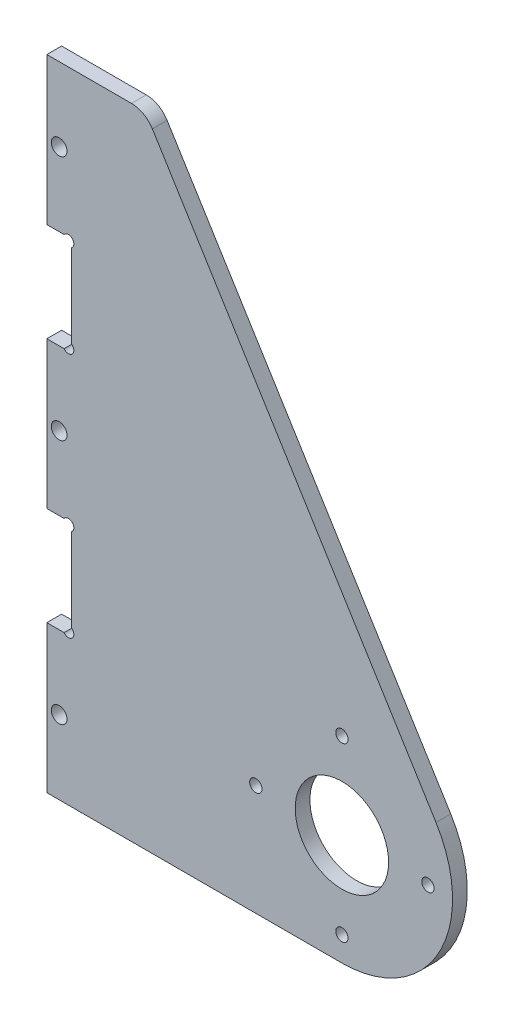
from build123d import *

# Parameters (mm, degrees)
SKETCH_2_R          = 9.5
SKETCH_2_R_2        = 1.25
EXTRUDE_1_DEPTH     = 3
FILLET_3_R          = 5
SKETCH_4_R          = 1.6
SKETCH_4_R_2        = 1.1
SKETCH_4_W          = 5.05
SKETCH_4_H          = 20.1
CUT_EXTRUDE_1_DEPTH = 10


with BuildPart() as part:
    # ｽｹｯﾁ2 → ﾎﾞｽ - 押し出し1 (new body)
    with BuildSketch(Plane.XY):
        with BuildLine():
            Line((-60, 107.5), (-60, -22.5))
            Line((-60, -22.5), (-40, -22.5))
            Line((-40, -22.5), (0, -22.5))
            ThreePointArc((0, -22.5), (19.65247344, -10.9558335), (19.138597944, 11.830641096))
            Line((19.138597944, 11.830641096), (-40, 107.5))
            Line((-40, 107.5), (-60, 107.5))
        make_face()
        Circle(SKETCH_2_R, mode=Mode.SUBTRACT)
        with Locations((0, 17.5)):
            Circle(SKETCH_2_R_2, mode=Mode.SUBTRACT)
        with Locations((17.5, 0)):
            Circle(SKETCH_2_R_2, mode=Mode.SUBTRACT)
        with Locations((0, -17.5)):
            Circle(SKETCH_2_R_2, mode=Mode.SUBTRACT)
        with Locations((-17.5, 0)):
            Circle(SKETCH_2_R_2, mode=Mode.SUBTRACT)
    extrude(amount=EXTRUDE_1_DEPTH)

    # ﾌｨﾚｯﾄ3
    fillet_3_edges = [part.edges().sort_by_distance(p)[0] for p in [
        (-40, 107.5, 1.5),
    ]]
    fillet(fillet_3_edges, radius=FILLET_3_R)

    # ｽｹｯﾁ4 → ｶｯﾄ - 押し出し1 (cut)
    with BuildSketch(Plane.XY.offset(3)):
        with Locations((-57.5, -7.5)):
            Circle(SKETCH_4_R)
        with Locations((-57.5, 42.5)):
            Circle(SKETCH_4_R)
        with Locations((-57.5, 92.5)):
            Circle(SKETCH_4_R)
        with Locations((-55.61, 26.89)):
            Circle(SKETCH_4_R_2)
        with Locations((-55.61, 8.11)):
            Circle(SKETCH_4_R_2)
        with Locations((-55.61, 58.11)):
            Circle(SKETCH_4_R_2)
        with Locations((-55.61, 76.89)):
            Circle(SKETCH_4_R_2)
        with Locations((-57.475, 67.5)):
            Rectangle(SKETCH_4_W, SKETCH_4_H)
        with Locations((-57.475, 17.5)):
            Rectangle(SKETCH_4_W, SKETCH_4_H)
    extrude(amount=-CUT_EXTRUDE_1_DEPTH, mode=Mode.SUBTRACT)


solid = part.part
